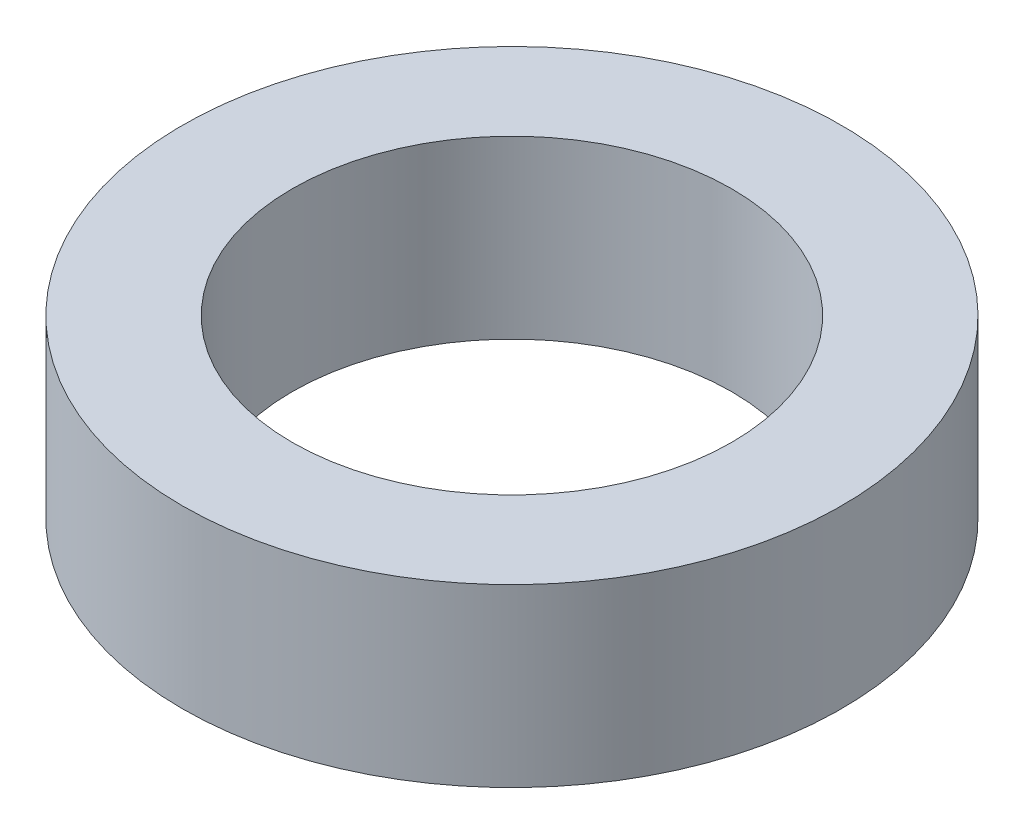
from build123d import *

# Parameters (mm, degrees)
SKETCH_1_R      = 2.999994
SKETCH_1_R_2    = 1.999996
EXTRUDE_1_DEPTH = 1.6


with BuildPart() as part:
    # 草图1 → 凸台-拉伸1 (new body)
    with BuildSketch(Plane(origin=(0, 0, 0), x_dir=(1, 0, 0), z_dir=(0, 1, 0))):
        Circle(SKETCH_1_R)
        Circle(SKETCH_1_R_2, mode=Mode.SUBTRACT)
    extrude(amount=EXTRUDE_1_DEPTH)


solid = part.part
